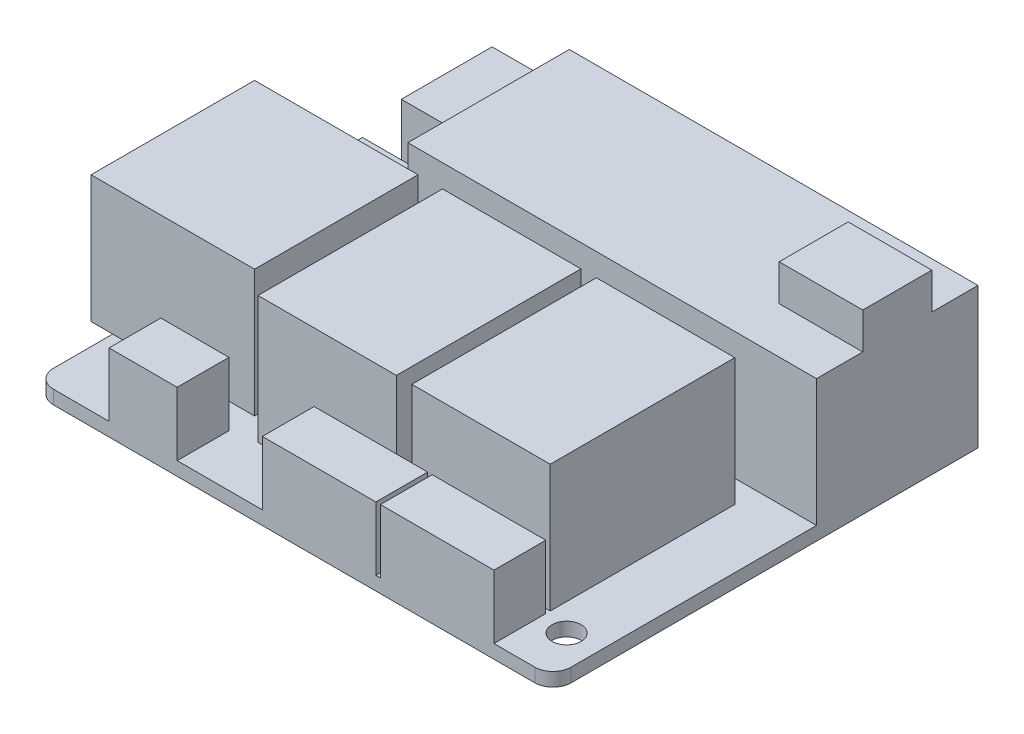
from build123d import *

# Parameters (mm, degrees)
SKETCH1_W             = 45
SKETCH1_H             = 17.78
BOSS_EXTRUDE1_DEPTH   = 14
SKETCH1_W_2           = 15.24
SKETCH1_H_2           = 20.32
BOSS_EXTRUDE1_2_DEPTH = 14
BOSS_EXTRUDE1_3_DEPTH = 14
SKETCH1_W_3           = 18
SKETCH1_H_3           = 18
BOSS_EXTRUDE1_4_DEPTH = 14
SKETCH2_W             = 12.5
SKETCH2_H             = 5.7
BOSS_EXTRUDE2_DEPTH   = 7
BOSS_EXTRUDE2_2_DEPTH = 7
SKETCH2_W_2           = 7.5
BOSS_EXTRUDE2_3_DEPTH = 7
SKETCH4_W             = 9
SKETCH4_H             = 27.5
BOSS_EXTRUDE4_DEPTH   = 5
SKETCH5_W             = 7.5
SKETCH5_H             = 10
BOSS_EXTRUDE5_DEPTH   = 10
SKETCH3_W             = 57
SKETCH3_H             = 46.8
SKETCH3_R             = 1.6
BOSS_EXTRUDE3_DEPTH   = 1.5
SKETCH6_W             = 9.2
SKETCH6_H             = 7.6
BOSS_EXTRUDE6_DEPTH   = 4
FILLET1_R             = 2


with BuildPart() as part:
    # Sketch1 → Boss-Extrude1 (new body)
    with BuildSketch(Plane(origin=(0, 0, 0), x_dir=(1, 0, 0), z_dir=(0, 1, 0))):
        with Locations((22.5, 8.89)):
            Rectangle(SKETCH1_W, SKETCH1_H)
    extrude(amount=BOSS_EXTRUDE1_DEPTH)



with BuildPart() as body_2:
    # Sketch1 → Boss-Extrude1 2 (new body)
    with BuildSketch(Plane(origin=(0, 0, 0), x_dir=(1, 0, 0), z_dir=(0, 1, 0))):
        with Locations((30.88, -12.66)):
            Rectangle(SKETCH1_W_2, SKETCH1_H_2)
    extrude(amount=BOSS_EXTRUDE1_2_DEPTH)


with BuildPart() as body_3:
    # Sketch1 → Boss-Extrude1 3 (new body)
    with BuildSketch(Plane(origin=(0, 0, 0), x_dir=(1, 0, 0), z_dir=(0, 1, 0))):
        with Locations((13.94, -12.66)):
            Rectangle(SKETCH1_W_2, SKETCH1_H_2)
    extrude(amount=BOSS_EXTRUDE1_3_DEPTH)


with BuildPart() as body_4:
    # Sketch1 → Boss-Extrude1 4 (new body)
    with BuildSketch(Plane(origin=(0, 0, 0), x_dir=(1, 0, 0), z_dir=(0, 1, 0))):
        with Locations((-5.38, -11.5)):
            Rectangle(SKETCH1_W_3, SKETCH1_H_3)
    extrude(amount=BOSS_EXTRUDE1_4_DEPTH)


with BuildPart() as body_5:
    # Sketch2 → Boss-Extrude2 (new body)
    with BuildSketch(Plane(origin=(0, 0, 0), x_dir=(1, 0, 0), z_dir=(0, 1, 0))):
        with Locations((32.25, -26.17)):
            Rectangle(SKETCH2_W, SKETCH2_H)
    extrude(amount=BOSS_EXTRUDE2_DEPTH)


with BuildPart() as body_6:
    # Sketch2 → Boss-Extrude2 2 (new body)
    with BuildSketch(Plane(origin=(0, 0, 0), x_dir=(1, 0, 0), z_dir=(0, 1, 0))):
        with Locations((19.25, -26.17)):
            Rectangle(SKETCH2_W, SKETCH2_H)
    extrude(amount=BOSS_EXTRUDE2_2_DEPTH)


with BuildPart() as body_7:
    # Sketch2 → Boss-Extrude2 3 (new body)
    with BuildSketch(Plane(origin=(0, 0, 0), x_dir=(1, 0, 0), z_dir=(0, 1, 0))):
        with Locations((-0.13, -26.17)):
            Rectangle(SKETCH2_W_2, SKETCH2_H)
    extrude(amount=BOSS_EXTRUDE2_3_DEPTH)


with BuildPart() as body_8:
    # Sketch4 → Boss-Extrude4 (new body)
    with BuildSketch(Plane(origin=(0, 0, 0), x_dir=(1, 0, 0), z_dir=(0, 1, 0))):
        with Locations((-7.5, -6.75)):
            Rectangle(SKETCH4_W, SKETCH4_H)
    extrude(amount=BOSS_EXTRUDE4_DEPTH)


with BuildPart() as body_9:
    # Sketch5 → Boss-Extrude5 (new body)
    with BuildSketch(Plane(origin=(0, 0, 0), x_dir=(1, 0, 0), z_dir=(0, 1, 0))):
        with Locations((-4.75, 12.78)):
            Rectangle(SKETCH5_W, SKETCH5_H)
    extrude(amount=BOSS_EXTRUDE5_DEPTH)


with BuildPart() as part_1:
    add(part.part)

    add(body_2.part)  # Boss-Extrude3 merges body 2

    add(body_3.part)  # Boss-Extrude3 merges body 3

    add(body_4.part)  # Boss-Extrude3 merges body 4

    add(body_5.part)  # Boss-Extrude3 merges body 5

    add(body_6.part)  # Boss-Extrude3 merges body 6

    add(body_7.part)  # Boss-Extrude3 merges body 7

    add(body_8.part)  # Boss-Extrude3 merges body 8

    add(body_9.part)  # Boss-Extrude3 merges body 9
    # Sketch3 → Boss-Extrude3 (add)
    with BuildSketch(Plane(origin=(0, 0, 0), x_dir=(1, 0, 0), z_dir=(0, 1, 0))):
        with Locations((16.5, -5.62)):
            Rectangle(SKETCH3_W, SKETCH3_H)
        with Locations((41.5, -24.02)):
            Circle(SKETCH3_R, mode=Mode.SUBTRACT)
        with Locations((41.5, 8.48)):
            Circle(SKETCH3_R, mode=Mode.SUBTRACT)
        with Locations((18.5, 8.48)):
            Circle(SKETCH3_R, mode=Mode.SUBTRACT)
    extrude(amount=-BOSS_EXTRUDE3_DEPTH)

    # Sketch6 → Boss-Extrude6 (add)
    with BuildSketch(Plane(origin=(0, 14, 0), x_dir=(1, 0, 0), z_dir=(0, 1, 0))):
        with Locations((40.4, 8.89)):
            Rectangle(SKETCH6_W, SKETCH6_H)
    extrude(amount=BOSS_EXTRUDE6_DEPTH)

    # Fillet1
    fillet1_edges = [part_1.edges().sort_by_distance(p)[0] for p in [
        (45, -0.75, 29.02),
        (-12, -0.75, 29.02),
        (-12, -0.75, -17.78),
    ]]
    fillet(fillet1_edges, radius=FILLET1_R)


solid = part_1.part
